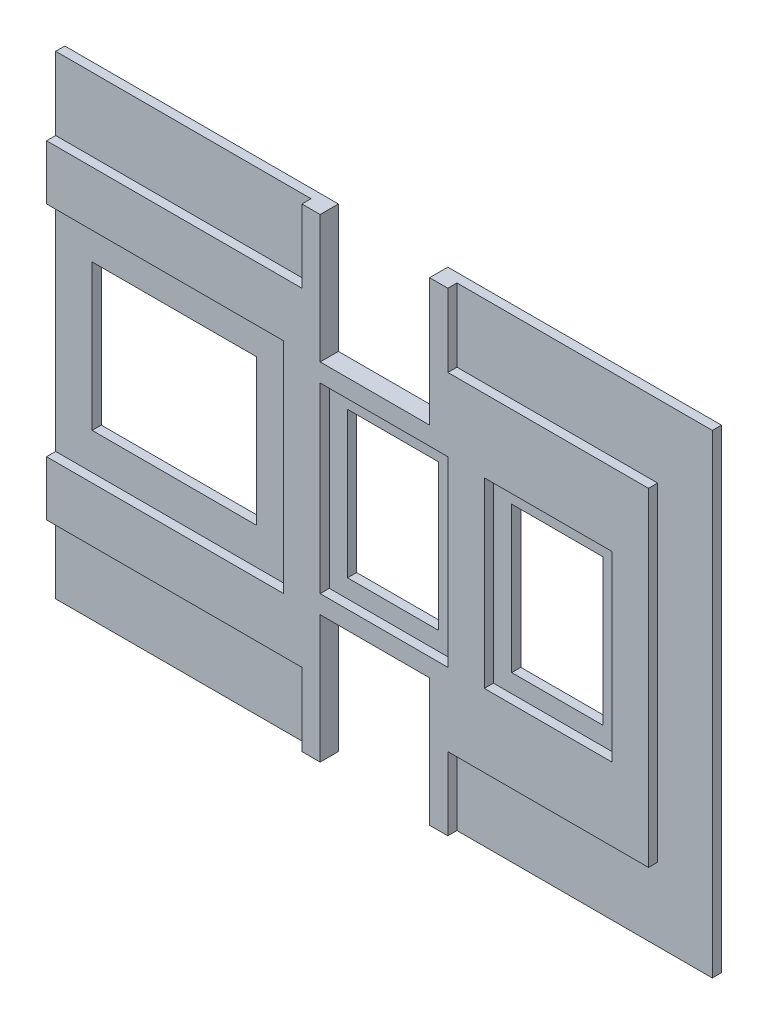
from build123d import *

# Parameters (mm, degrees)
SKETCH1_W               = 180
SKETCH1_H               = 130
BOSS_EXTRUDE1_DEPTH     = 5
SKETCH2_W               = 70
SKETCH2_H               = 20
CUT_EXTRUDE1_DEPTH      = 2.5
SKETCH3_W               = 65
SKETCH3_H               = 60
SKETCH3_W_2             = 35
SKETCH3_H_2             = 50
CUT_EXTRUDE2_DEPTH      = 2.5
CUT_EXTRUDE3_DEPTH      = 2.5
CUT_EXTRUDE3_DEPTH_BACK = 112.046161573
SKETCH4_W               = 30
SKETCH4_H               = 35
SKETCH4_W_2             = 45
SKETCH4_H_2             = 40
SKETCH4_W_3             = 25
SKETCH5_W               = 15
SKETCH5_H               = 90
CUT_EXTRUDE4_DEPTH      = 2.5


with BuildPart() as part:
    # Sketch1 → Boss-Extrude1 (new body)
    with BuildSketch(Plane.XY):
        Rectangle(SKETCH1_W, SKETCH1_H)
    extrude(amount=BOSS_EXTRUDE1_DEPTH)

    # Sketch2 → Cut-Extrude1 (cut)
    with BuildSketch(Plane.XY.offset(5)):
        with Locations((-55, 55)):
            Rectangle(SKETCH2_W, SKETCH2_H)
        with Locations((55, 55)):
            Rectangle(SKETCH2_W, SKETCH2_H)
        with Locations((55, -55)):
            Rectangle(SKETCH2_W, SKETCH2_H)
        with Locations((-55, -55)):
            Rectangle(SKETCH2_W, SKETCH2_H)
    extrude(amount=-CUT_EXTRUDE1_DEPTH, mode=Mode.SUBTRACT)

    # Sketch3 → Cut-Extrude2 (cut)
    with BuildSketch(Plane.XY.offset(5)):
        with Locations((-57.5, 0)):
            Rectangle(SKETCH3_W, SKETCH3_H)
        with Locations((2.5, 0)):
            Rectangle(SKETCH3_W_2, SKETCH3_H_2)
        with Locations((47.5, 0)):
            Rectangle(SKETCH3_W_2, SKETCH3_H_2)
    extrude(amount=-CUT_EXTRUDE2_DEPTH, mode=Mode.SUBTRACT)

    # Sketch4 → Cut-Extrude3 (cut, two sides: drawn at the far end of the back side and taken through both)
    with BuildSketch(Plane.XY.offset(2.5).offset(-CUT_EXTRUDE3_DEPTH_BACK)):
        with Locations((0, 47.5)):
            Rectangle(SKETCH4_W, SKETCH4_H)
        with Locations((0, -47.5)):
            Rectangle(SKETCH4_W, SKETCH4_H)
        with Locations((-57.5, 0)):
            Rectangle(SKETCH4_W_2, SKETCH4_H_2)
        with Locations((47.5, 0)):
            Rectangle(SKETCH4_W_3, SKETCH4_H_2)
        with Locations((2.5, 0)):
            Rectangle(SKETCH4_W_3, SKETCH4_H_2)
    extrude(amount=CUT_EXTRUDE3_DEPTH + CUT_EXTRUDE3_DEPTH_BACK, mode=Mode.SUBTRACT)

    # Sketch5 → Cut-Extrude4 (cut)
    with BuildSketch(Plane.XY.offset(5)):
        with Locations((82.5, 0)):
            Rectangle(SKETCH5_W, SKETCH5_H)
    extrude(amount=-CUT_EXTRUDE4_DEPTH, mode=Mode.SUBTRACT)


solid = part.part
